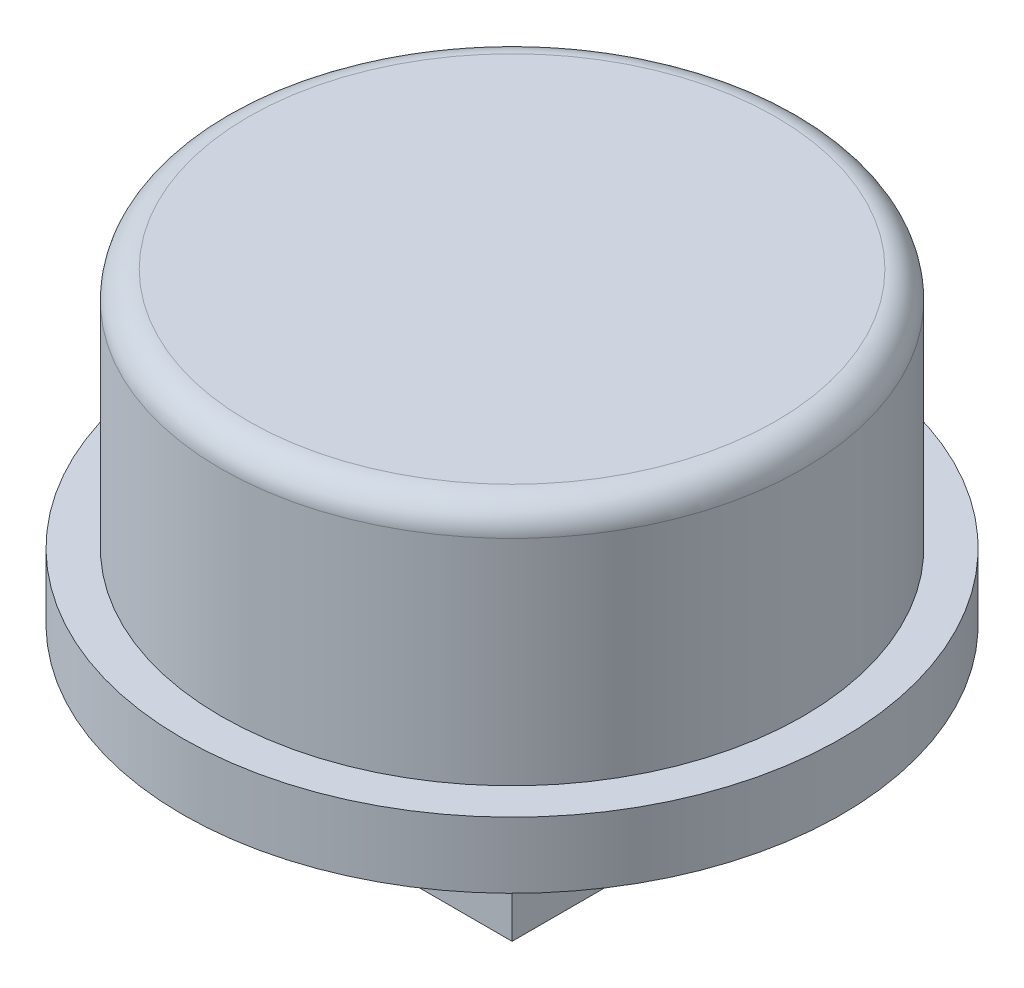
from build123d import *

# Parameters (mm, degrees)
SKETCH2_R           = 6
BOSS_EXTRUDE1_DEPTH = 5.6
SKETCH3_R           = 6
SKETCH3_R_2         = 5.3
CUT_EXTRUDE1_DEPTH  = 4.4
FILLET1_R           = 0.5
SKETCH4_W           = 5
SKETCH4_H           = 5
SKETCH4_W_2         = 4
SKETCH4_H_2         = 4
BOSS_EXTRUDE2_DEPTH = 2.5


with BuildPart() as part:
    # Sketch2 → Boss-Extrude1 (new body)
    with BuildSketch(Plane(origin=(0, 0, 0), x_dir=(1, 0, 0), z_dir=(0, 1, 0))):
        Circle(SKETCH2_R)
    extrude(amount=BOSS_EXTRUDE1_DEPTH)

    # Sketch3 → Cut-Extrude1 (cut)
    with BuildSketch(Plane(origin=(0, 5.6, 0), x_dir=(1, 0, 0), z_dir=(0, 1, 0))):
        Circle(SKETCH3_R)
        Circle(SKETCH3_R_2, mode=Mode.SUBTRACT)
    extrude(amount=-CUT_EXTRUDE1_DEPTH, mode=Mode.SUBTRACT)

    # Fillet1
    fillet1_edges = [part.edges().sort_by_distance(p)[0] for p in [
        (-5.3, 5.6, 0),
    ]]
    fillet(fillet1_edges, radius=FILLET1_R)

    # Sketch4 → Boss-Extrude2 (add)
    with BuildSketch(Plane.XZ):
        Rectangle(SKETCH4_W, SKETCH4_H)
        Rectangle(SKETCH4_W_2, SKETCH4_H_2, mode=Mode.SUBTRACT)
    extrude(amount=BOSS_EXTRUDE2_DEPTH)


solid = part.part
